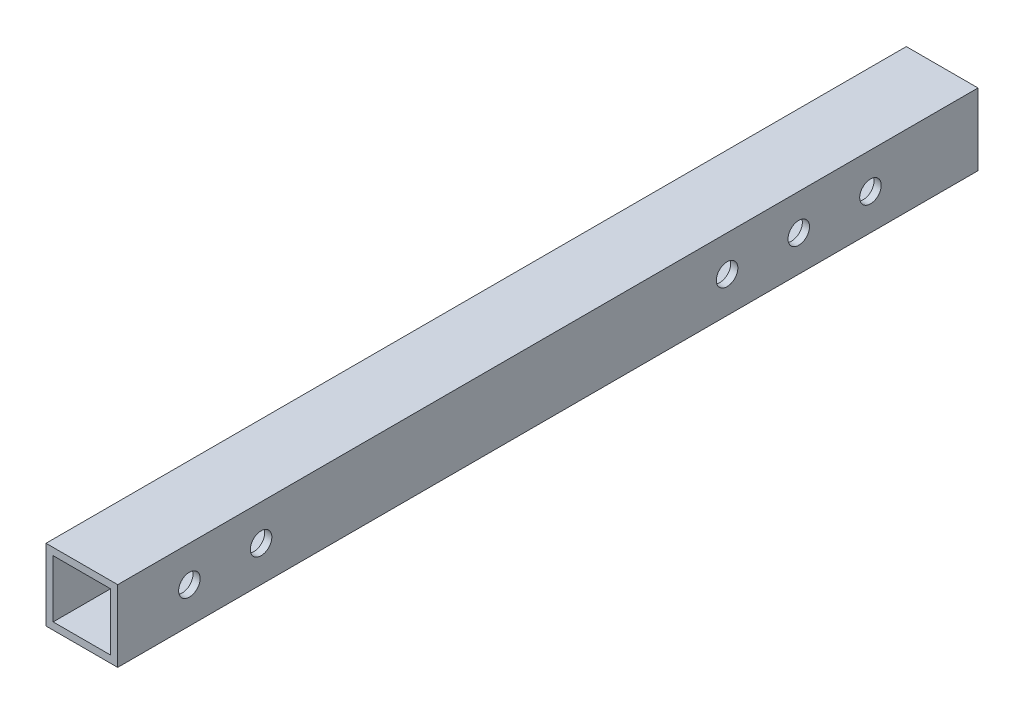
from build123d import *

# Parameters (mm, degrees)
SKETCH_1_W          = 120
SKETCH_1_H          = 10
SKETCH_1_R          = 1.5
EXTRUDE_1_DEPTH     = 10
SKETCH_2_W          = 8
SKETCH_2_H          = 8
CUT_EXTRUDE_1_DEPTH = 120


with BuildPart() as part:
    # 草图1 → 凸台-拉伸1 (new body)
    with BuildSketch(Plane(origin=(0, 0, 0), x_dir=(0, 0, -1), z_dir=(1, 0, 0))):
        with Locations((13.354414341, 5)):
            Rectangle(SKETCH_1_W, SKETCH_1_H)
        with Locations((-36.645585659, 5)):
            Circle(SKETCH_1_R, mode=Mode.SUBTRACT)
        with Locations((-26.645585659, 5)):
            Circle(SKETCH_1_R, mode=Mode.SUBTRACT)
        with Locations((58.354414341, 5)):
            Circle(SKETCH_1_R, mode=Mode.SUBTRACT)
        with Locations((48.354414341, 5)):
            Circle(SKETCH_1_R, mode=Mode.SUBTRACT)
        with Locations((38.354414341, 5)):
            Circle(SKETCH_1_R, mode=Mode.SUBTRACT)
    extrude(amount=EXTRUDE_1_DEPTH)

    # 草图2 → 切除-拉伸1 (cut)
    with BuildSketch(Plane(origin=(0, 0, -73.354414341), x_dir=(-1, 0, 0), z_dir=(0, 0, -1))):
        with Locations((-5, 5)):
            Rectangle(SKETCH_2_W, SKETCH_2_H)
    extrude(amount=-CUT_EXTRUDE_1_DEPTH, mode=Mode.SUBTRACT)


solid = part.part
